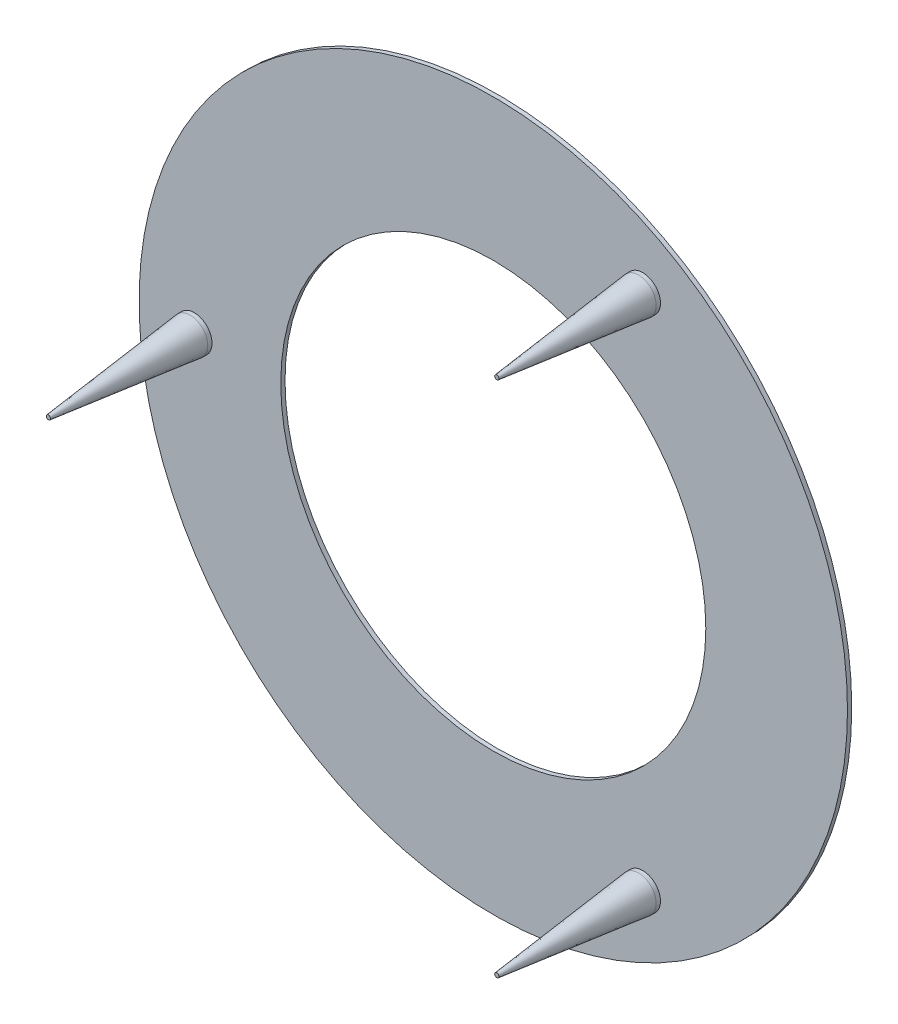
from build123d import *

# Parameters (mm, degrees)
SKETCH1_R                     = 63.5
SKETCH1_R_2                   = 38.1
BOSS_EXTRUDE1_DEPTH           = 0.762
SKETCH2_R                     = 3.175
BOSS_EXTRUDE2_DEPTH           = 26.162
CHAMFER1_SIZE                 = 25.4
CHAMFER1_SIZE2                = 2.794
CIRPATTERN3_COUNT             = 3
CHAMFER1_OF_CIRPATTERN3_SIZE2 = 2.794
CHAMFER1_OF_CIRPATTERN3_SIZE  = 25.4


with BuildPart() as part:
    # Sketch1 → Boss-Extrude1 (new body)
    with BuildSketch(Plane.XY):
        Circle(SKETCH1_R)
        Circle(SKETCH1_R_2, mode=Mode.SUBTRACT)
    extrude(amount=BOSS_EXTRUDE1_DEPTH)

    # Sketch2 → Boss-Extrude2 (add)
    with BuildSketch(Plane.XY.offset(0.762)):
        with Locations((-53.597287335, 0)):
            Circle(SKETCH2_R)
    boss_extrude2 = extrude(amount=BOSS_EXTRUDE2_DEPTH)

    # Chamfer1
    chamfer1_edges = [part.edges().sort_by_distance(p)[0] for p in [
        (-56.772287335, 0, 26.924),
    ]]
    chamfer1_side = [part.faces().sort_by_distance(p)[0] for p in [
        (-56.772287335, 0, 13.843),
    ]]
    chamfer(chamfer1_edges, length=CHAMFER1_SIZE, length2=CHAMFER1_SIZE2, reference=chamfer1_side[0])

    # CirPattern3: Boss-Extrude2 ×3 about axis
    cirpattern3_axis = Axis((0, 0, 0), (0, 0, 1))
    for i in range(1, CIRPATTERN3_COUNT):
        add(boss_extrude2.rotate(cirpattern3_axis, i * 360 / CIRPATTERN3_COUNT))

    # Chamfer1 of CirPattern3
    chamfer1_of_cirpattern3_edges = [part.edges().sort_by_distance(p)[0] for p in [
        (28.386143667, -49.166243063, 26.924),
        (28.386143667, 49.166243063, 26.924),
    ]]
    chamfer(chamfer1_of_cirpattern3_edges, length=CHAMFER1_OF_CIRPATTERN3_SIZE, length2=CHAMFER1_OF_CIRPATTERN3_SIZE2)


solid = part.part
